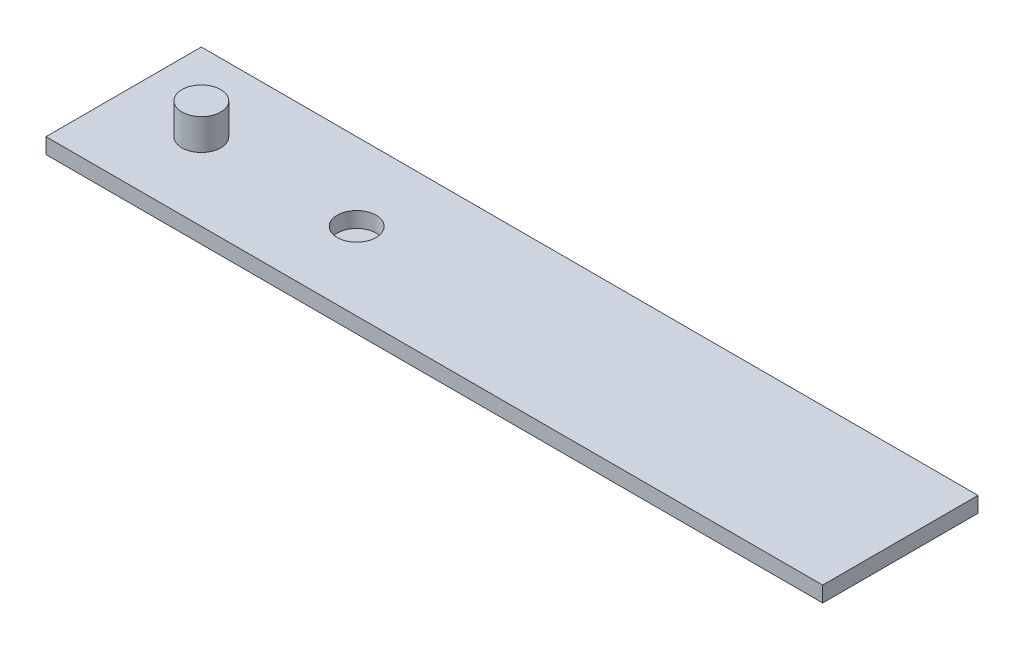
from build123d import *

# Parameters (mm, degrees)
SKETCH2_W           = 127
SKETCH2_H           = 25.4
SKETCH2_R           = 3.175
BOSS_EXTRUDE1_DEPTH = 2.54
SKETCH2_2_R         = 3.175
BOSS_EXTRUDE2_DEPTH = 7.62
SKETCH2_3_R         = 3.175
BOSS_EXTRUDE3_DEPTH = 2.54


with BuildPart() as part:
    # Sketch2 → Boss-Extrude1 (new body)
    with BuildSketch(Plane(origin=(0, 0, 0), x_dir=(1, 0, 0), z_dir=(0, 1, 0))):
        with Locations((63.5, 12.7)):
            Rectangle(SKETCH2_W, SKETCH2_H)
        with Locations((12.7, 12.7)):
            Circle(SKETCH2_R, mode=Mode.SUBTRACT)
        with Locations((38.1, 12.7)):
            Circle(SKETCH2_R, mode=Mode.SUBTRACT)
    extrude(amount=BOSS_EXTRUDE1_DEPTH)

    # Sketch2_2 → Boss-Extrude2 (add)
    with BuildSketch(Plane(origin=(0, 0, 0), x_dir=(1, 0, 0), z_dir=(0, 1, 0))):
        with Locations((12.7, 12.7)):
            Circle(SKETCH2_2_R)
    extrude(amount=BOSS_EXTRUDE2_DEPTH)


with BuildPart() as body_2:
    # Sketch2_3 → Boss-Extrude3 (new body)
    with BuildSketch(Plane(origin=(0, 0, 0), x_dir=(1, 0, 0), z_dir=(0, 1, 0))):
        with Locations((38.1, 12.7)):
            Circle(SKETCH2_3_R)
    extrude(amount=-BOSS_EXTRUDE3_DEPTH)


solid = Compound([part.part, body_2.part])
